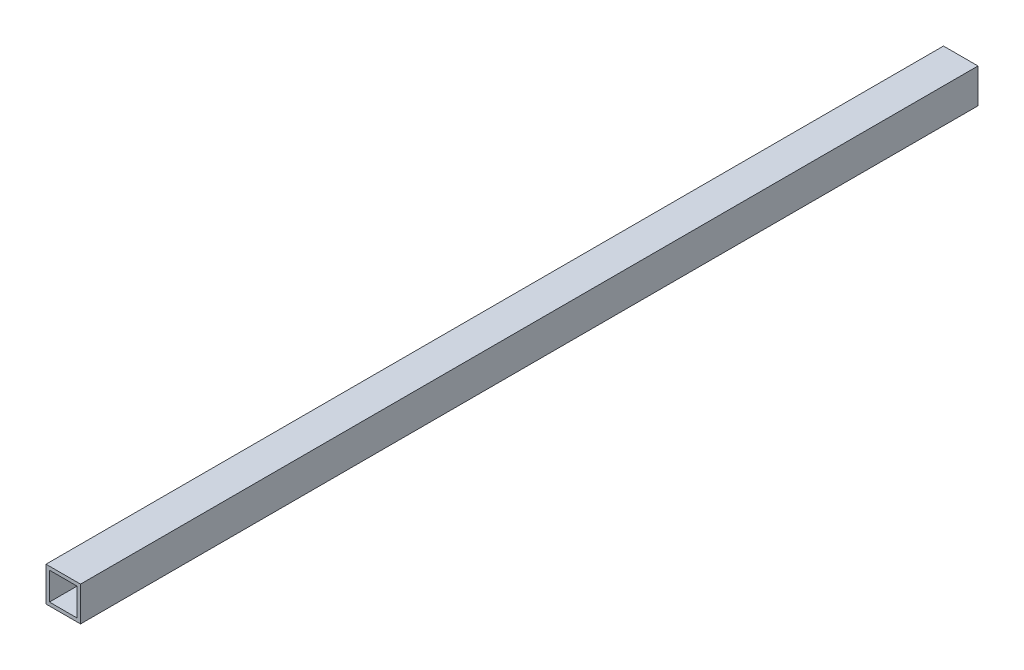
from build123d import *

# Parameters (mm, degrees)
SKETCH_3_W               = 20
SKETCH_3_H               = 20
EXTRUDE_1_DEPTH          = 500
SKETCH_6_W               = 16
SKETCH_6_H               = 16
CUT_EXTRUDE_3_DEPTH      = 560
SKETCH_8_W               = 20
SKETCH_8_H               = 20
SKETCH_8_W_2             = 16
SKETCH_8_H_2             = 16
EXTRUDE_3_DEPTH          = 20
SKETCH_12_R              = 1
CUT_EXTRUDE_7_DEPTH      = 10
M4X0_7_1_D               = 3.3
M4X0_7_1_DEPTH           = 11.5
M4X0_7_1_TIP             = 0.991420021
M4X0_7_1_ON_FACE_2_D     = 3.3
M4X0_7_1_ON_FACE_2_DEPTH = 11.5
M4X0_7_1_ON_FACE_2_TIP   = 0.991420021


with BuildPart() as part:
    # ｽｹｯﾁ3 → ﾎﾞｽ - 押し出し1 (new body)
    with BuildSketch(Plane.XY):
        Rectangle(SKETCH_3_W, SKETCH_3_H)
    extrude(amount=EXTRUDE_1_DEPTH)

    # ｽｹｯﾁ6 → ｶｯﾄ - 押し出し3 (cut)
    with BuildSketch(Plane.XY.offset(500)):
        Rectangle(SKETCH_6_W, SKETCH_6_H)
    extrude(amount=-CUT_EXTRUDE_3_DEPTH, mode=Mode.SUBTRACT)

    # ｽｹｯﾁ8 → ﾎﾞｽ - 押し出し3 (add)
    with BuildSketch(Plane.XY.offset(500)):
        Rectangle(SKETCH_8_W, SKETCH_8_H)
        Rectangle(SKETCH_8_W_2, SKETCH_8_H_2, mode=Mode.SUBTRACT)
    extrude(amount=EXTRUDE_3_DEPTH)

    # ｽｹｯﾁ12 → ｶｯﾄ - 押し出し7 (cut)
    with BuildSketch(Plane.ZY.offset(10)):
        with Locations((20, 0)):
            Circle(SKETCH_12_R)
        with Locations((500, 0)):
            Circle(SKETCH_12_R)
    extrude(amount=-CUT_EXTRUDE_7_DEPTH, mode=Mode.SUBTRACT)

    # M4x0.7 ねじ穴1
    with Locations(Plane(origin=(-10, 0, 20), x_dir=(0, -1, 0), z_dir=(-1, 0, 0))):
        with Locations((0, 0)):
            Hole(M4X0_7_1_D / 2, depth=M4X0_7_1_DEPTH)
            with Locations((0, 0, -(M4X0_7_1_DEPTH + M4X0_7_1_TIP / 2))):  # 118° drill point
                Cone(0, M4X0_7_1_D / 2, M4X0_7_1_TIP, mode=Mode.SUBTRACT)

    # M4x0.7 ねじ穴1 on face 2
    with Locations(Plane(origin=(-8, 0, 500), x_dir=(0, -1, 0), z_dir=(-1, 0, 0))):
        with Locations((0, 0)):
            Hole(M4X0_7_1_ON_FACE_2_D / 2, depth=M4X0_7_1_ON_FACE_2_DEPTH)
            with Locations((0, 0, -(M4X0_7_1_ON_FACE_2_DEPTH + M4X0_7_1_ON_FACE_2_TIP / 2))):  # 118° drill point
                Cone(0, M4X0_7_1_ON_FACE_2_D / 2, M4X0_7_1_ON_FACE_2_TIP, mode=Mode.SUBTRACT)


solid = part.part
